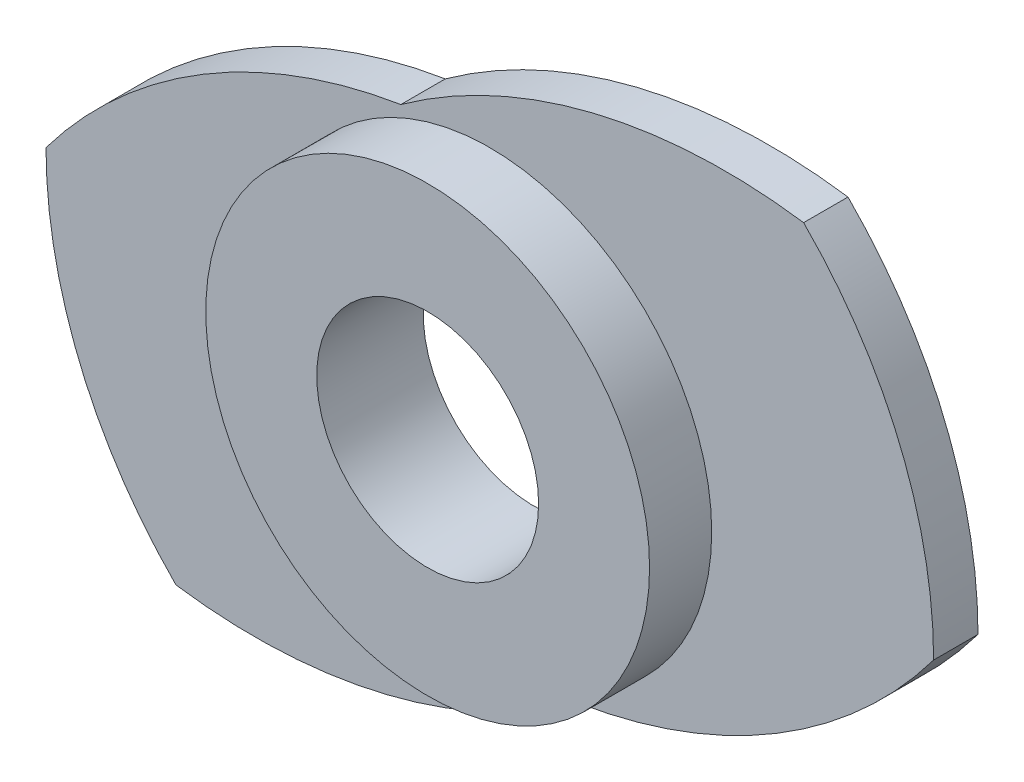
from build123d import *

# Parameters (mm, degrees)
BOSS_EXTRUDE1_DEPTH = 1
SKETCH2_R           = 5
BOSS_EXTRUDE2_DEPTH = 1.4
SKETCH3_R           = 2.5
CUT_EXTRUDE1_DEPTH  = 8


with BuildPart() as part:
    # Sketch1 → Boss-Extrude1 (new body)
    with BuildSketch(Plane.XY):
        with BuildLine():
            ThreePointArc((-2.00408914, 4.838299183), (-6.471230468, 3.194539552), (-10, 0))
            ThreePointArc((-10, 0), (-9.238795325, -3.826834324), (-7.071067812, -7.071067812))
            ThreePointArc((-7.071067812, -7.071067812), (-2.316970366, -6.834731526), (2.00408914, -4.838299183))
            ThreePointArc((2.00408914, -4.838299183), (6.471230468, -3.194539552), (10, 0))
            ThreePointArc((10, 0), (9.238795325, 3.826834324), (7.071067812, 7.071067812))
            ThreePointArc((7.071067812, 7.071067812), (2.316970366, 6.834731526), (-2.00408914, 4.838299183))
        make_face()
    extrude(amount=BOSS_EXTRUDE1_DEPTH)

    # Sketch2 → Boss-Extrude2 (add)
    with BuildSketch(Plane.XY.offset(1)):
        Circle(SKETCH2_R)
    extrude(amount=BOSS_EXTRUDE2_DEPTH)

    # Sketch3 → Cut-Extrude1 (cut)
    with BuildSketch(Plane.XY.offset(2.4)):
        Circle(SKETCH3_R)
    extrude(amount=-CUT_EXTRUDE1_DEPTH, mode=Mode.SUBTRACT)


solid = part.part
